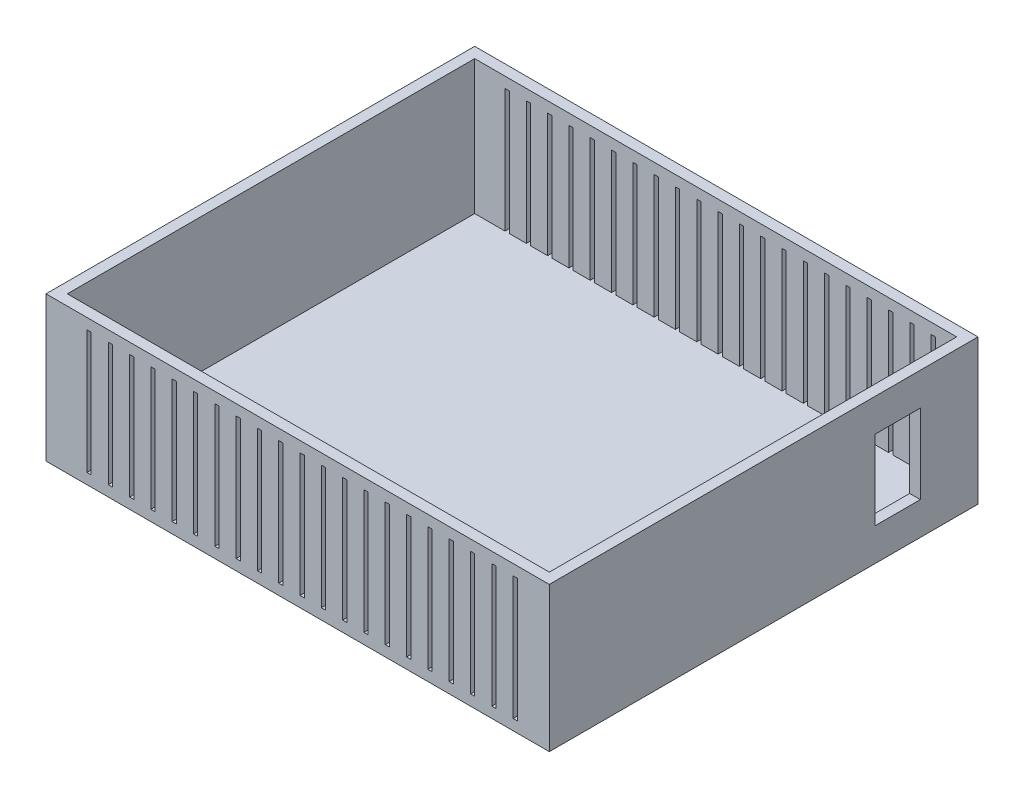
from build123d import *

# Parameters (mm, degrees)
SKETCH1_W           = 300
SKETCH1_H           = 255.524
SKETCH1_W_2         = 287.3
SKETCH1_H_2         = 242.824
BOSS_EXTRUDE1_DEPTH = 80
SKETCH2_W           = 300
SKETCH2_H           = 255.524
BOSS_EXTRUDE2_DEPTH = 6.35
SKETCH4_W           = 27.03
SKETCH4_H           = 47.25
CUT_EXTRUDE1_DEPTH  = 6.35
SKETCH5_W           = 2.54
SKETCH5_H           = 73.65
BOSS_EXTRUDE4_DEPTH = 324.866
LPATTERN2_COUNT     = 21
LPATTERN2_PITCH     = 12.7


with BuildPart() as part:
    # Sketch1 → Boss-Extrude1 (new body)
    with BuildSketch(Plane(origin=(0, 0, 0), x_dir=(1, 0, 0), z_dir=(0, 1, 0))):
        Rectangle(SKETCH1_W, SKETCH1_H)
        Rectangle(SKETCH1_W_2, SKETCH1_H_2, mode=Mode.SUBTRACT)
    extrude(amount=BOSS_EXTRUDE1_DEPTH)

    # Sketch2 → Boss-Extrude2 (add)
    with BuildSketch(Plane.XZ):
        Rectangle(SKETCH2_W, SKETCH2_H)
    extrude(amount=BOSS_EXTRUDE2_DEPTH)

    # Sketch4 → Cut-Extrude1 (cut)
    with BuildSketch(Plane(origin=(150, 0, 0), x_dir=(0, 0, -1), z_dir=(1, 0, 0))):
        with Locations((79.878215203, 36.825)):
            Rectangle(SKETCH4_W, SKETCH4_H)
    extrude(amount=-CUT_EXTRUDE1_DEPTH, mode=Mode.SUBTRACT)


with BuildPart() as body_2:
    # Sketch5 → Boss-Extrude4 (new body)
    with BuildSketch(Plane(origin=(0, 0, -127.762), x_dir=(-1, 0, 0), z_dir=(0, 0, -1))):
        with Locations((-129.68, 36.825)):
            Rectangle(SKETCH5_W, SKETCH5_H)
    boss_extrude4 = extrude(amount=-BOSS_EXTRUDE4_DEPTH)


with BuildPart() as lpattern2_1:
    # LPattern2: pattern copy
    add(boss_extrude4.moved(Location(Vector(-1, 0, 0) * (1 * LPATTERN2_PITCH))))


with BuildPart() as lpattern2_2:
    # LPattern2: pattern copy
    add(boss_extrude4.moved(Location(Vector(-1, 0, 0) * (2 * LPATTERN2_PITCH))))


with BuildPart() as lpattern2_3:
    # LPattern2: pattern copy
    add(boss_extrude4.moved(Location(Vector(-1, 0, 0) * (3 * LPATTERN2_PITCH))))


with BuildPart() as lpattern2_4:
    # LPattern2: pattern copy
    add(boss_extrude4.moved(Location(Vector(-1, 0, 0) * (4 * LPATTERN2_PITCH))))


with BuildPart() as lpattern2_5:
    # LPattern2: pattern copy
    add(boss_extrude4.moved(Location(Vector(-1, 0, 0) * (5 * LPATTERN2_PITCH))))


with BuildPart() as lpattern2_6:
    # LPattern2: pattern copy
    add(boss_extrude4.moved(Location(Vector(-1, 0, 0) * (6 * LPATTERN2_PITCH))))


with BuildPart() as lpattern2_7:
    # LPattern2: pattern copy
    add(boss_extrude4.moved(Location(Vector(-1, 0, 0) * (7 * LPATTERN2_PITCH))))


with BuildPart() as lpattern2_8:
    # LPattern2: pattern copy
    add(boss_extrude4.moved(Location(Vector(-1, 0, 0) * (8 * LPATTERN2_PITCH))))


with BuildPart() as lpattern2_9:
    # LPattern2: pattern copy
    add(boss_extrude4.moved(Location(Vector(-1, 0, 0) * (9 * LPATTERN2_PITCH))))


with BuildPart() as lpattern2_10:
    # LPattern2: pattern copy
    add(boss_extrude4.moved(Location(Vector(-1, 0, 0) * (10 * LPATTERN2_PITCH))))


with BuildPart() as lpattern2_11:
    # LPattern2: pattern copy
    add(boss_extrude4.moved(Location(Vector(-1, 0, 0) * (11 * LPATTERN2_PITCH))))


with BuildPart() as lpattern2_12:
    # LPattern2: pattern copy
    add(boss_extrude4.moved(Location(Vector(-1, 0, 0) * (12 * LPATTERN2_PITCH))))


with BuildPart() as lpattern2_13:
    # LPattern2: pattern copy
    add(boss_extrude4.moved(Location(Vector(-1, 0, 0) * (13 * LPATTERN2_PITCH))))


with BuildPart() as lpattern2_14:
    # LPattern2: pattern copy
    add(boss_extrude4.moved(Location(Vector(-1, 0, 0) * (14 * LPATTERN2_PITCH))))


with BuildPart() as lpattern2_15:
    # LPattern2: pattern copy
    add(boss_extrude4.moved(Location(Vector(-1, 0, 0) * (15 * LPATTERN2_PITCH))))


with BuildPart() as lpattern2_16:
    # LPattern2: pattern copy
    add(boss_extrude4.moved(Location(Vector(-1, 0, 0) * (16 * LPATTERN2_PITCH))))


with BuildPart() as lpattern2_17:
    # LPattern2: pattern copy
    add(boss_extrude4.moved(Location(Vector(-1, 0, 0) * (17 * LPATTERN2_PITCH))))


with BuildPart() as lpattern2_18:
    # LPattern2: pattern copy
    add(boss_extrude4.moved(Location(Vector(-1, 0, 0) * (18 * LPATTERN2_PITCH))))


with BuildPart() as lpattern2_19:
    # LPattern2: pattern copy
    add(boss_extrude4.moved(Location(Vector(-1, 0, 0) * (19 * LPATTERN2_PITCH))))


with BuildPart() as lpattern2_20:
    # LPattern2: pattern copy
    add(boss_extrude4.moved(Location(Vector(-1, 0, 0) * (20 * LPATTERN2_PITCH))))


with BuildPart() as part_1:
    add(part.part)

    # Combine2: cut LPattern2_11, body 2, LPattern2_1, LPattern2_2, LPattern2_4, LPattern2_3, LPattern2_5, LPattern2_6, LPattern2_7, LPattern2_8, LPattern2_10, LPattern2_9, LPattern2_12, LPattern2_13, LPattern2_15, LPattern2_16, LPattern2_19, LPattern2_20, LPattern2_18, LPattern2_17, LPattern2_14
    add(lpattern2_11.part, mode=Mode.SUBTRACT)
    add(body_2.part, mode=Mode.SUBTRACT)
    add(lpattern2_1.part, mode=Mode.SUBTRACT)
    add(lpattern2_2.part, mode=Mode.SUBTRACT)
    add(lpattern2_4.part, mode=Mode.SUBTRACT)
    add(lpattern2_3.part, mode=Mode.SUBTRACT)
    add(lpattern2_5.part, mode=Mode.SUBTRACT)
    add(lpattern2_6.part, mode=Mode.SUBTRACT)
    add(lpattern2_7.part, mode=Mode.SUBTRACT)
    add(lpattern2_8.part, mode=Mode.SUBTRACT)
    add(lpattern2_10.part, mode=Mode.SUBTRACT)
    add(lpattern2_9.part, mode=Mode.SUBTRACT)
    add(lpattern2_12.part, mode=Mode.SUBTRACT)
    add(lpattern2_13.part, mode=Mode.SUBTRACT)
    add(lpattern2_15.part, mode=Mode.SUBTRACT)
    add(lpattern2_16.part, mode=Mode.SUBTRACT)
    add(lpattern2_19.part, mode=Mode.SUBTRACT)
    add(lpattern2_20.part, mode=Mode.SUBTRACT)
    add(lpattern2_18.part, mode=Mode.SUBTRACT)
    add(lpattern2_17.part, mode=Mode.SUBTRACT)
    add(lpattern2_14.part, mode=Mode.SUBTRACT)


solid = part_1.part
